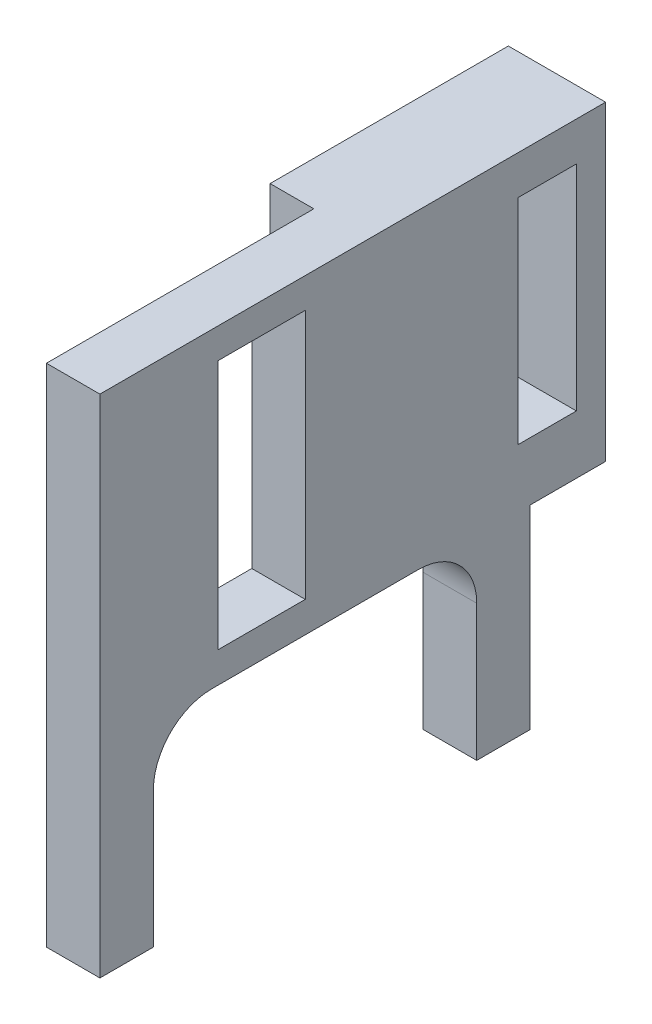
from build123d import *

# Parameters (mm, degrees)
SKETCH1_W           = 52
SKETCH1_H           = 32
BOSS_EXTRUDE1_DEPTH = 10
SKETCH7_W           = 4.5
SKETCH7_H           = 40
CUT_EXTRUDE3_DEPTH  = 33
SKETCH70_W          = 5.5
SKETCH70_H          = 44.25
BOSS_EXTRUDE4_DEPTH = 20
SKETCH20_W          = 5.5
SKETCH20_H          = 33.25
CUT_EXTRUDE9_DEPTH  = 21
FILLET1_R           = 6
FILLET2_R           = 6
SKETCH49_W          = 4.5
SKETCH49_H          = 32
BOSS_EXTRUDE3_DEPTH = 12.5
SKETCH50_W          = 4.5
SKETCH50_H          = 24.5
CUT_EXTRUDE19_DEPTH = 3
SKETCH35_W          = 9
SKETCH35_H          = 25.742086546
CUT_EXTRUDE15_DEPTH = 6.5
SKETCH67_W          = 5
SKETCH67_H          = 25.742086546
CUT_EXTRUDE22_DEPTH = 3
SKETCH68_W          = 5
SKETCH68_H          = 25.742086546
CUT_EXTRUDE23_DEPTH = 3
SKETCH63_W          = 6
SKETCH63_H          = 22
CUT_EXTRUDE24_DEPTH = 11
SKETCH76_W          = 10.5
SKETCH76_H          = 22
CUT_EXTRUDE25_DEPTH = 7


with BuildPart() as part:
    # Sketch1 → Boss-Extrude1 (new body)
    with BuildSketch(Plane(origin=(0, 0, 0), x_dir=(0, 0, -1), z_dir=(1, 0, 0))):
        Rectangle(SKETCH1_W, SKETCH1_H)
    extrude(amount=BOSS_EXTRUDE1_DEPTH)

    # Sketch7 → Cut-Extrude3 (cut, through all)
    with BuildSketch(Plane(origin=(0, 16, 0), x_dir=(1, 0, 0), z_dir=(0, 1, 0))):
        with Locations((2.25, 6)):
            Rectangle(SKETCH7_W, SKETCH7_H)
    extrude(amount=-CUT_EXTRUDE3_DEPTH, mode=Mode.SUBTRACT)

    # Sketch70 → Boss-Extrude4 (add)
    with BuildSketch(Plane(origin=(0, -16, 0), x_dir=(-1, 0, 0), z_dir=(0, -1, 0))):
        with Locations((-7.25, 3.875)):
            Rectangle(SKETCH70_W, SKETCH70_H)
    extrude(amount=BOSS_EXTRUDE4_DEPTH)

    # Sketch20 → Cut-Extrude9 (cut, through all)
    with BuildSketch(Plane(origin=(0, -16, 0), x_dir=(-1, 0, 0), z_dir=(0, -1, 0))):
        with Locations((-7.25, 3.875)):
            Rectangle(SKETCH20_W, SKETCH20_H)
    extrude(amount=CUT_EXTRUDE9_DEPTH, mode=Mode.SUBTRACT)

    # Fillet1
    fillet1_edges = [part.edges().sort_by_distance(p)[0] for p in [
        (7.25, -16, -20.5),
    ]]
    fillet(fillet1_edges, radius=FILLET1_R)

    # Fillet2
    fillet2_edges = [part.edges().sort_by_distance(p)[0] for p in [
        (7.25, -16, 12.75),
    ]]
    fillet(fillet2_edges, radius=FILLET2_R)

    # Sketch49 → Boss-Extrude3 (add)
    with BuildSketch(Plane(origin=(0, 0, 14), x_dir=(-1, 0, 0), z_dir=(0, 0, -1))):
        with Locations((-2.25, 0)):
            Rectangle(SKETCH49_W, SKETCH49_H)
    extrude(amount=BOSS_EXTRUDE3_DEPTH)

    # Sketch50 → Cut-Extrude19 (cut)
    with BuildSketch(Plane.XZ.offset(16)):
        with Locations((2.25, 13.75)):
            Rectangle(SKETCH50_W, SKETCH50_H)
    extrude(amount=-CUT_EXTRUDE19_DEPTH, mode=Mode.SUBTRACT)

    # Sketch35 → Cut-Extrude15 (cut, through all)
    with BuildSketch(Plane.ZY.offset(-4.5)):
        with Locations((-9.381446742, 0.030527838)):
            Rectangle(SKETCH35_W, SKETCH35_H)
    extrude(amount=-CUT_EXTRUDE15_DEPTH, mode=Mode.SUBTRACT)

    # Sketch67 → Cut-Extrude22 (cut)
    with BuildSketch(Plane.ZY.offset(-4.5)):
        with Locations((-18.381446742, 0.030527838)):
            Rectangle(SKETCH67_W, SKETCH67_H)
    extrude(amount=-CUT_EXTRUDE22_DEPTH, mode=Mode.SUBTRACT)

    # Sketch68 → Cut-Extrude23 (cut)
    with BuildSketch(Plane.ZY.offset(-4.5)):
        with Locations((-0.381446742, 0.030527838)):
            Rectangle(SKETCH68_W, SKETCH68_H)
    extrude(amount=-CUT_EXTRUDE23_DEPTH, mode=Mode.SUBTRACT)

    # Sketch63 → Cut-Extrude24 (cut, through all)
    with BuildSketch(Plane.ZY):
        with Locations((20, 1)):
            Rectangle(SKETCH63_W, SKETCH63_H)
    extrude(amount=-CUT_EXTRUDE24_DEPTH, mode=Mode.SUBTRACT)

    # Sketch76 → Cut-Extrude25 (cut)
    with BuildSketch(Plane.ZY):
        with Locations((9.75, 1)):
            Rectangle(SKETCH76_W, SKETCH76_H)
    extrude(amount=-CUT_EXTRUDE25_DEPTH, mode=Mode.SUBTRACT)


with BuildPart() as body_2:
    # Mirror1: mirrored copy
    add(part.part.mirror(Plane(origin=(10, 16, 26), x_dir=(1, 0, 0), z_dir=(0, 0, -1))))


solid = body_2.part
